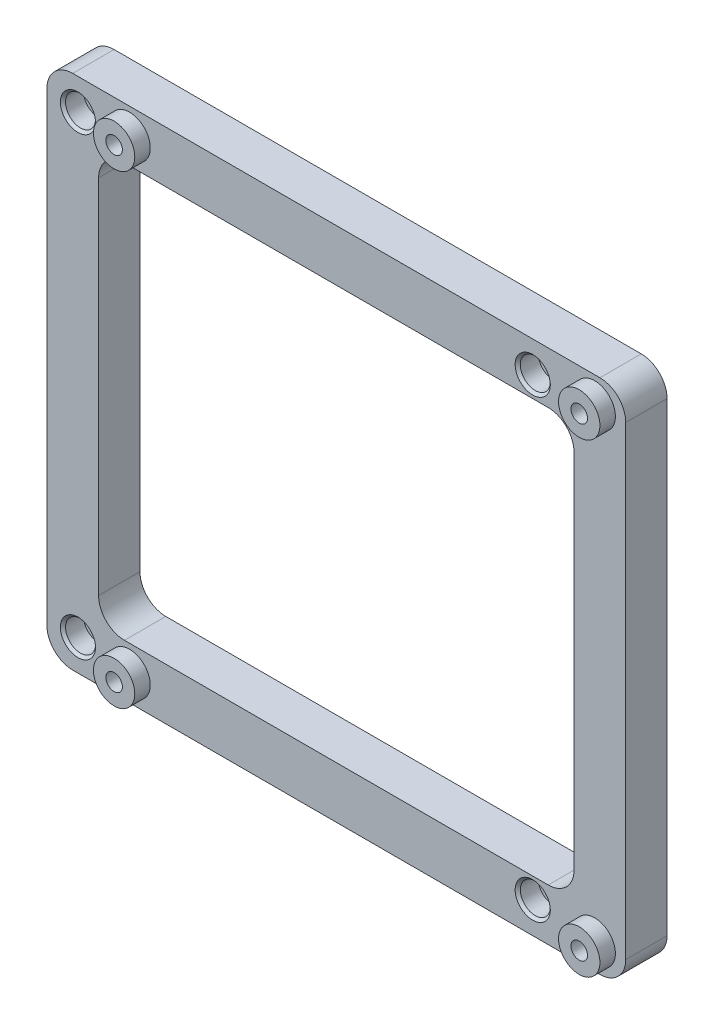
from build123d import *

# Parameters (mm, degrees)
SKICA1_W                 = 112
SKICA1_H                 = 100
SKICA1_R                 = 1.6
SKICA1_W_2               = 92
SKICA1_H_2               = 80
P_IDAT_VYSUNUT_M1_DEPTH  = 8
SKICA2_R                 = 2.9
ODEBRAT_VYSUNUT_M1_DEPTH = 4
SKICA3_R                 = 1.6
P_IDAT_VYSUNUT_M2_DEPTH  = 4
ZKOSEN_1_SIZE            = 0.5
ZAOBLIT1_R               = 5
SKICA4_R                 = 4
SKICA4_R_2               = 1.6
P_IDAT_VYSUNUT_M3_DEPTH  = 3


with BuildPart() as part:
    # Skica1 → Přidat vysunutím1 (new body)
    with BuildSketch(Plane.XY):
        with Locations((6, 0)):
            Rectangle(SKICA1_W, SKICA1_H)
        with Locations((-44, 44)):
            Circle(SKICA1_R, mode=Mode.SUBTRACT)
        with Locations((44, 44)):
            Circle(SKICA1_R, mode=Mode.SUBTRACT)
        with Locations((-44, -44)):
            Circle(SKICA1_R, mode=Mode.SUBTRACT)
        with Locations((44, -44)):
            Circle(SKICA1_R, mode=Mode.SUBTRACT)
        Polygon((-34, 41.766838493), (-31.2, 43.383419246), (-31.2, 46.616580754), (-34, 48.233161507), (-36.8, 46.616580754), (-36.8, 43.383419246), align=None, mode=Mode.SUBTRACT)
        Polygon((56, 41.766838493), (58.8, 43.383419246), (58.8, 46.616580754), (56, 48.233161507), (53.2, 46.616580754), (53.2, 43.383419246), align=None, mode=Mode.SUBTRACT)
        Polygon((53.2, -43.383419246), (56, -41.766838493), (58.8, -43.383419246), (58.8, -46.616580754), (56, -48.233161507), (53.2, -46.616580754), align=None, mode=Mode.SUBTRACT)
        Polygon((-36.8, -43.383419246), (-34, -41.766838493), (-31.2, -43.383419246), (-31.2, -46.616580754), (-34, -48.233161507), (-36.8, -46.616580754), align=None, mode=Mode.SUBTRACT)
        with Locations((6, 0)):
            Rectangle(SKICA1_W_2, SKICA1_H_2, mode=Mode.SUBTRACT)
    extrude(amount=P_IDAT_VYSUNUT_M1_DEPTH)

    # Skica2 → Odebrat vysunutím1 (cut)
    with BuildSketch(Plane.XY.offset(8)):
        with Locations((-44, 44)):
            Circle(SKICA2_R)
        with Locations((44, 44)):
            Circle(SKICA2_R)
        with Locations((44, -44)):
            Circle(SKICA2_R)
        with Locations((-44, -44)):
            Circle(SKICA2_R)
    extrude(amount=-ODEBRAT_VYSUNUT_M1_DEPTH, mode=Mode.SUBTRACT)

    # Skica3 → Přidat vysunutím2 (add)
    with BuildSketch(Plane.XY.offset(8)):
        Polygon((-31.2, -46.616580754), (-31.2, -43.383419246), (-34, -41.766838493), (-36.8, -43.383419246), (-36.8, -46.616580754), (-34, -48.233161507), align=None)
        with Locations((-34, -45)):
            Circle(SKICA3_R, mode=Mode.SUBTRACT)
        Polygon((58.8, -46.616580754), (58.8, -43.383419246), (56, -41.766838493), (53.2, -43.383419246), (53.2, -46.616580754), (56, -48.233161507), align=None)
        with Locations((56, -45)):
            Circle(SKICA3_R, mode=Mode.SUBTRACT)
        Polygon((53.2, 46.616580754), (53.2, 43.383419246), (56, 41.766838493), (58.8, 43.383419246), (58.8, 46.616580754), (56, 48.233161507), align=None)
        with Locations((56, 45)):
            Circle(SKICA3_R, mode=Mode.SUBTRACT)
        Polygon((-34, 48.233161507), (-36.8, 46.616580754), (-36.8, 43.383419246), (-34, 41.766838493), (-31.2, 43.383419246), (-31.2, 46.616580754), align=None)
        with Locations((-34, 45)):
            Circle(SKICA3_R, mode=Mode.SUBTRACT)
    extrude(amount=-P_IDAT_VYSUNUT_M2_DEPTH)

    # Zkosení1
    zkosen_1_edges = [part.edges().sort_by_distance(p)[0] for p in [
        (-46.9, -44, 8),
        (41.1, -44, 8),
        (41.1, 44, 8),
        (-46.9, 44, 8),
    ]]
    chamfer(zkosen_1_edges, length=ZKOSEN_1_SIZE)

    # Zaoblit1
    zaoblit1_edges = [part.edges().sort_by_distance(p)[0] for p in [
        (-40, 40, 4),
        (-40, -40, 4),
        (52, -40, 4),
        (52, 40, 4),
        (-50, 50, 4),
        (62, 50, 4),
        (62, -50, 4),
        (-50, -50, 4),
    ]]
    fillet(zaoblit1_edges, radius=ZAOBLIT1_R)

    # Skica4 → Přidat vysunutím3 (add)
    with BuildSketch(Plane.XY.offset(8)):
        with Locations((-34, 45)):
            Circle(SKICA4_R)
        with Locations((-34, 45)):
            Circle(SKICA4_R_2, mode=Mode.SUBTRACT)
        with Locations((56, 45)):
            Circle(SKICA4_R)
        with Locations((56, 45)):
            Circle(SKICA4_R_2, mode=Mode.SUBTRACT)
        with Locations((56, -45)):
            Circle(SKICA4_R)
        with Locations((56, -45)):
            Circle(SKICA4_R_2, mode=Mode.SUBTRACT)
        with Locations((-34, -45)):
            Circle(SKICA4_R)
        with Locations((-34, -45)):
            Circle(SKICA4_R_2, mode=Mode.SUBTRACT)
    extrude(amount=P_IDAT_VYSUNUT_M3_DEPTH)


solid = part.part
